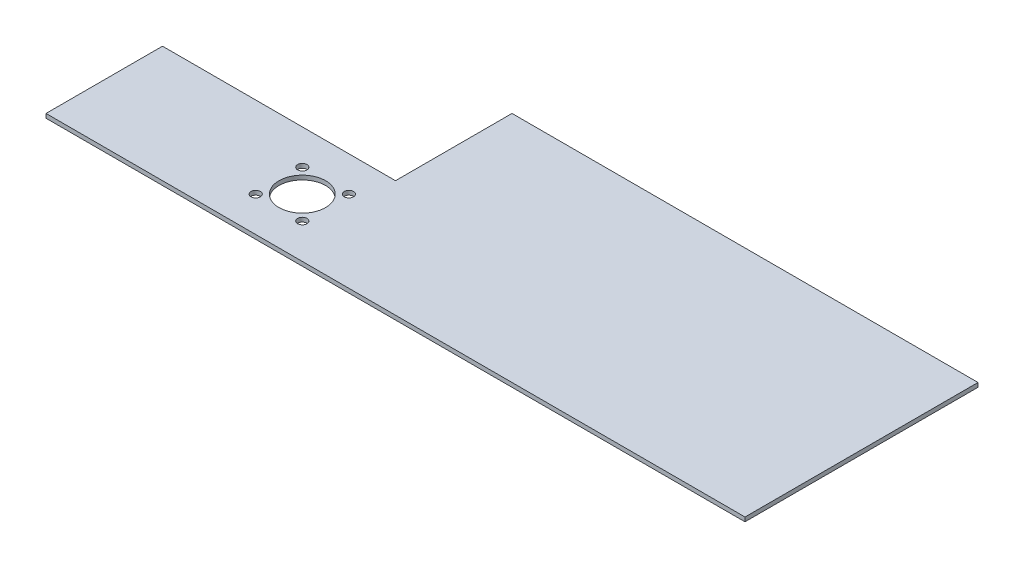
from build123d import *

# Parameters (mm, degrees)
SKETCH_1_W          = 300
SKETCH_1_H          = 100
EXTRUDE_1_DEPTH     = 1.8
SKETCH_2_W          = 100
SKETCH_2_H          = 50
CUT_EXTRUDE_1_DEPTH = 2.8
SKETCH_3_R          = 2
SKETCH_3_R_2        = 10
CUT_EXTRUDE_2_DEPTH = 2.8


with BuildPart() as part:
    # 草图1 → 凸台-拉伸1 (new body)
    with BuildSketch(Plane(origin=(0, 0, 0), x_dir=(1, 0, 0), z_dir=(0, 1, 0))):
        with Locations((150, 50)):
            Rectangle(SKETCH_1_W, SKETCH_1_H)
    extrude(amount=EXTRUDE_1_DEPTH)

    # 草图2 → 切除-拉伸1 (cut, through all)
    with BuildSketch(Plane(origin=(0, 1.8, 0), x_dir=(1, 0, 0), z_dir=(0, 1, 0))):
        with Locations((50, 75)):
            Rectangle(SKETCH_2_W, SKETCH_2_H)
    extrude(amount=-CUT_EXTRUDE_1_DEPTH, mode=Mode.SUBTRACT)

    # 草图3 → 切除-拉伸2 (cut, through all)
    with BuildSketch(Plane(origin=(0, 1.8, 0), x_dir=(1, 0, 0), z_dir=(0, 1, 0))):
        with Locations((95, 35)):
            Circle(SKETCH_3_R)
        with Locations((75, 35)):
            Circle(SKETCH_3_R)
        with Locations((75, 15)):
            Circle(SKETCH_3_R)
        with Locations((95, 15)):
            Circle(SKETCH_3_R)
        with Locations((85, 25)):
            Circle(SKETCH_3_R_2)
    extrude(amount=-CUT_EXTRUDE_2_DEPTH, mode=Mode.SUBTRACT)


solid = part.part
